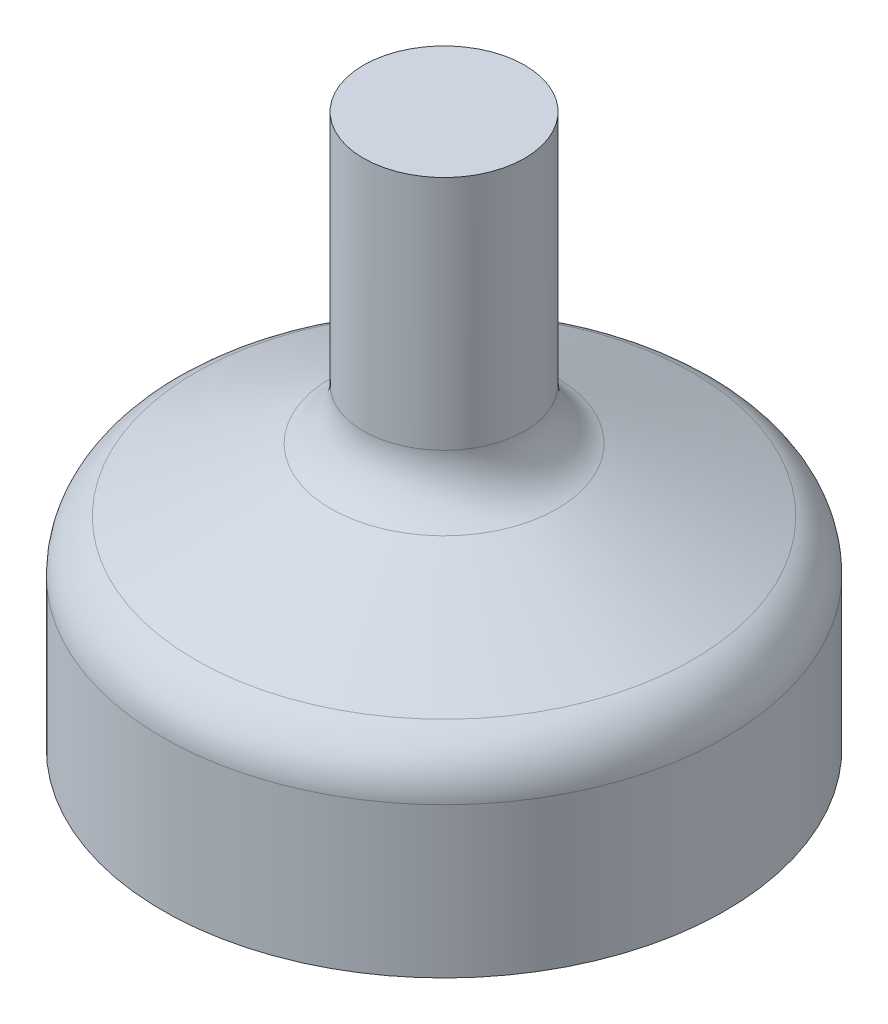
from build123d import *

# Parameters (mm, degrees)
SKETCH8_R           = 1.075
BOSS_EXTRUDE1_DEPTH = 1.15


with BuildPart() as part:
    # Sketch6 → Revolve-Thin2 (revolve)
    with BuildSketch(Plane(origin=(0, 0, 0), x_dir=(0, 0, -1), z_dir=(1, 0, 0))):
        with BuildLine():
            Line((-3.75, 0), (-3.75, 2))
            ThreePointArc((-3.75, 2), (-3.632270634, 2.403402832), (-3.31604308, 2.680159372))
            Line((-3.31604308, 2.680159372), (-1.50895692, 3.519840628))
            ThreePointArc((-1.50895692, 3.519840628), (-1.192729366, 3.796597168), (-1.075, 4.2))
            Line((-1.075, 4.2), (-1.075, 6.2))
            Line((-1.075, 6.2), (-0.425, 6.2))
            Line((-0.425, 6.2), (-0.425, 4.2))
            ThreePointArc((-0.425, 4.2), (-0.644761483, 3.44698138), (-1.235052917, 2.930369172))
            Line((-1.235052917, 2.930369172), (-3.042139077, 2.090687916))
            ThreePointArc((-3.042139077, 2.090687916), (-3.084302751, 2.053787044), (-3.1, 2))
            Line((-3.1, 2), (-3.1, 0))
            Line((-3.1, 0), (-3.75, 0))
        make_face()
    revolve(axis=Axis((0, -0.227579974, 0), (0, 1, 0)))

    # Sketch8 → Boss-Extrude1 (add)
    with BuildSketch(Plane(origin=(0, 6.2, 0), x_dir=(1, 0, 0), z_dir=(0, 1, 0))):
        Circle(SKETCH8_R)
    extrude(amount=BOSS_EXTRUDE1_DEPTH)


solid = part.part
